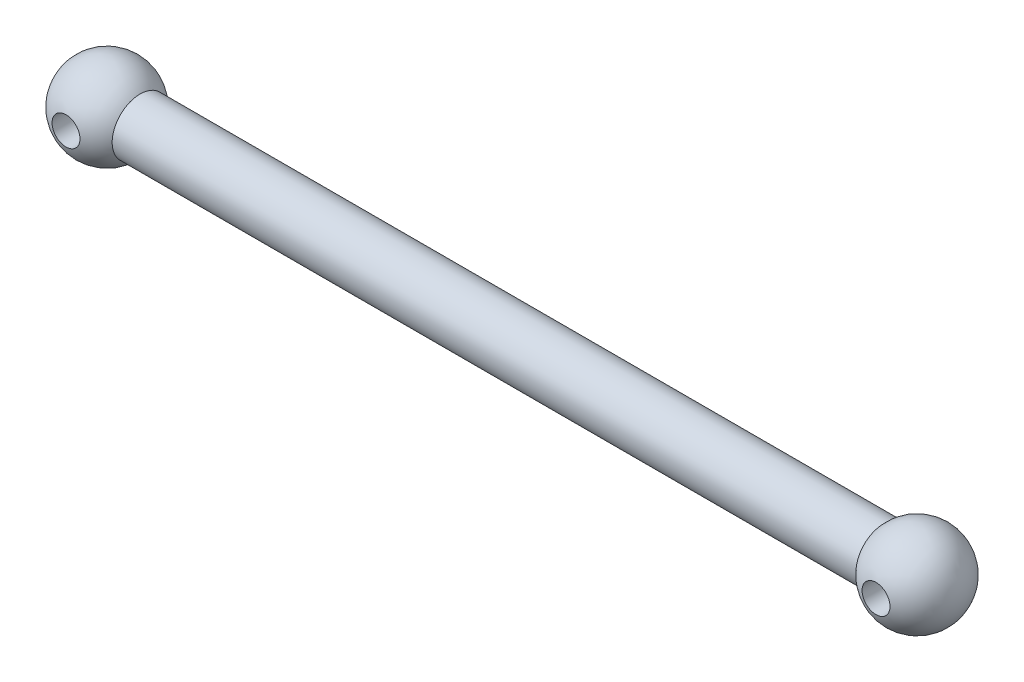
from build123d import *

# Parameters (mm, degrees)
SKETCH2_R               = 1
CUT_EXTRUDE1_DEPTH      = 4.1
CUT_EXTRUDE1_DEPTH_BACK = 4.1


with BuildPart() as part:
    # Sketch1 one side → Revolve2 (revolve)
    with BuildSketch(Plane(origin=(0, 0, 0), x_dir=(1, 0, 0), z_dir=(0, 1, 0))):
        with BuildLine():
            ThreePointArc((32.1, 0), (30.06478027, 2.911398801), (26.631456144, 2))
            Line((26.631456144, 2), (-26.631456144, 2))
            ThreePointArc((-26.631456144, 2), (-30.06478027, 2.911398801), (-32.1, 0))
            Line((-32.1, 0), (32.1, 0))
        make_face()
    revolve(axis=Axis((-29, 0, 0), (1, 0, 0)))

    # Sketch2 → Cut-Extrude1 (cut, two sides)
    with BuildSketch(Plane.XY) as cut_extrude1_sk:
        with Locations((29, 0)):
            Circle(SKETCH2_R)
        with Locations((-29, 0)):
            Circle(SKETCH2_R)
    extrude(amount=CUT_EXTRUDE1_DEPTH, mode=Mode.SUBTRACT)
    extrude(cut_extrude1_sk.sketch, amount=-CUT_EXTRUDE1_DEPTH_BACK, mode=Mode.SUBTRACT)


solid = part.part
